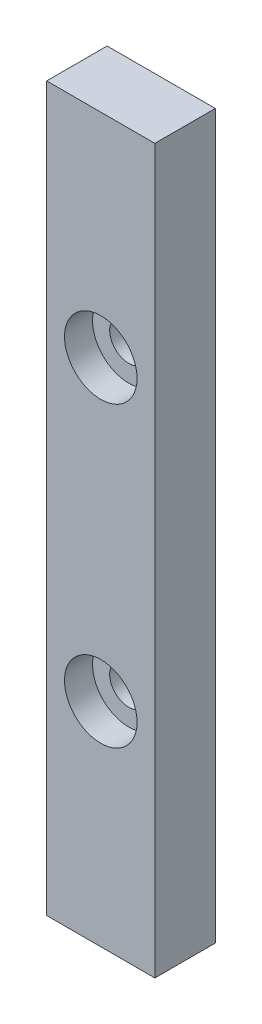
from build123d import *

# Parameters (mm, degrees)
SKETCH1_W                 = 8.5
SKETCH1_H                 = 56.8
BOSS_EXTRUDE1_DEPTH       = 4.75
F_3_0MM_DOWEL_HOLE1_D     = 3
F_3_0MM_DOWEL_HOLE1_DEPTH = 5
F_3_0MM_DOWEL_HOLE1_TIP   = 0.901290929
SKETCH6_R                 = 2.85
CUT_EXTRUDE1_DEPTH        = 2.2


with BuildPart() as part:
    # Sketch1 → Boss-Extrude1 (new body)
    with BuildSketch(Plane.XY):
        with Locations((4.25, -28.4)):
            Rectangle(SKETCH1_W, SKETCH1_H)
    extrude(amount=BOSS_EXTRUDE1_DEPTH)

    # Ø3.0mm Dowel Hole1
    with Locations(Plane.XY.offset(4.75)):
        with Locations((4.25, -16.7), (4.25, -40.1)):
            Hole(F_3_0MM_DOWEL_HOLE1_D / 2, depth=F_3_0MM_DOWEL_HOLE1_DEPTH)
            with Locations((0, 0, -(F_3_0MM_DOWEL_HOLE1_DEPTH + F_3_0MM_DOWEL_HOLE1_TIP / 2))):  # 118° drill point
                Cone(0, F_3_0MM_DOWEL_HOLE1_D / 2, F_3_0MM_DOWEL_HOLE1_TIP, mode=Mode.SUBTRACT)

    # Sketch6 → Cut-Extrude1 (cut)
    with BuildSketch(Plane.XY.offset(4.75)):
        with Locations((4.25, -16.7)):
            Circle(SKETCH6_R)
        with Locations((4.25, -40.1)):
            Circle(SKETCH6_R)
    extrude(amount=-CUT_EXTRUDE1_DEPTH, mode=Mode.SUBTRACT)


solid = part.part
